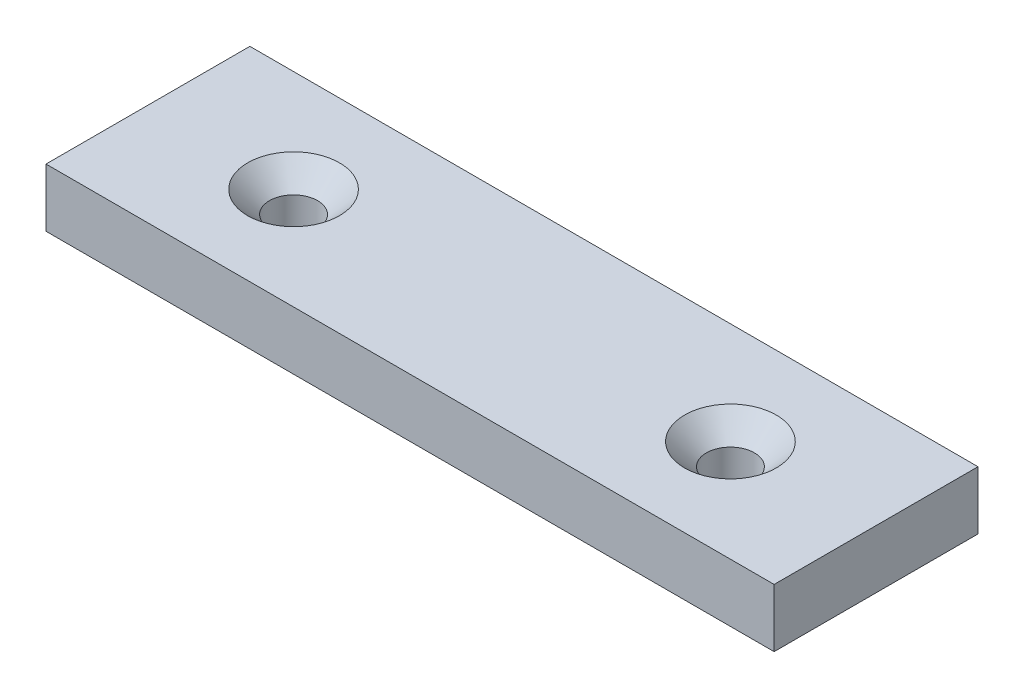
from build123d import *

# Parameters (mm, degrees)
SKETCH1_W                                       = 100
SKETCH1_H                                       = 28
BOSS_EXTRUDE1_DEPTH                             = 8
CSK_FOR_M6_FLAT_HEAD_MACHINE_SCREW1_D           = 6.6
CSK_FOR_M6_FLAT_HEAD_MACHINE_SCREW1_DEPTH       = 8
CSK_FOR_M6_FLAT_HEAD_MACHINE_SCREW1_CSINK_D     = 12.6
CSK_FOR_M6_FLAT_HEAD_MACHINE_SCREW1_CSINK_ANGLE = 90


with BuildPart() as part:
    # Sketch1 → Boss-Extrude1 (new body)
    with BuildSketch(Plane(origin=(0, 0, 0), x_dir=(1, 0, 0), z_dir=(0, 1, 0))):
        Rectangle(SKETCH1_W, SKETCH1_H)
    extrude(amount=BOSS_EXTRUDE1_DEPTH)

    # CSK for M6 Flat Head Machine Screw1
    with Locations(Plane(origin=(0, 8, 0), x_dir=(-1, 0, 0), z_dir=(0, 1, 0))):
        with Locations((-30, 0), (30, 0)):
            CounterSinkHole(CSK_FOR_M6_FLAT_HEAD_MACHINE_SCREW1_D / 2, CSK_FOR_M6_FLAT_HEAD_MACHINE_SCREW1_CSINK_D / 2, depth=CSK_FOR_M6_FLAT_HEAD_MACHINE_SCREW1_DEPTH, counter_sink_angle=CSK_FOR_M6_FLAT_HEAD_MACHINE_SCREW1_CSINK_ANGLE)


solid = part.part
